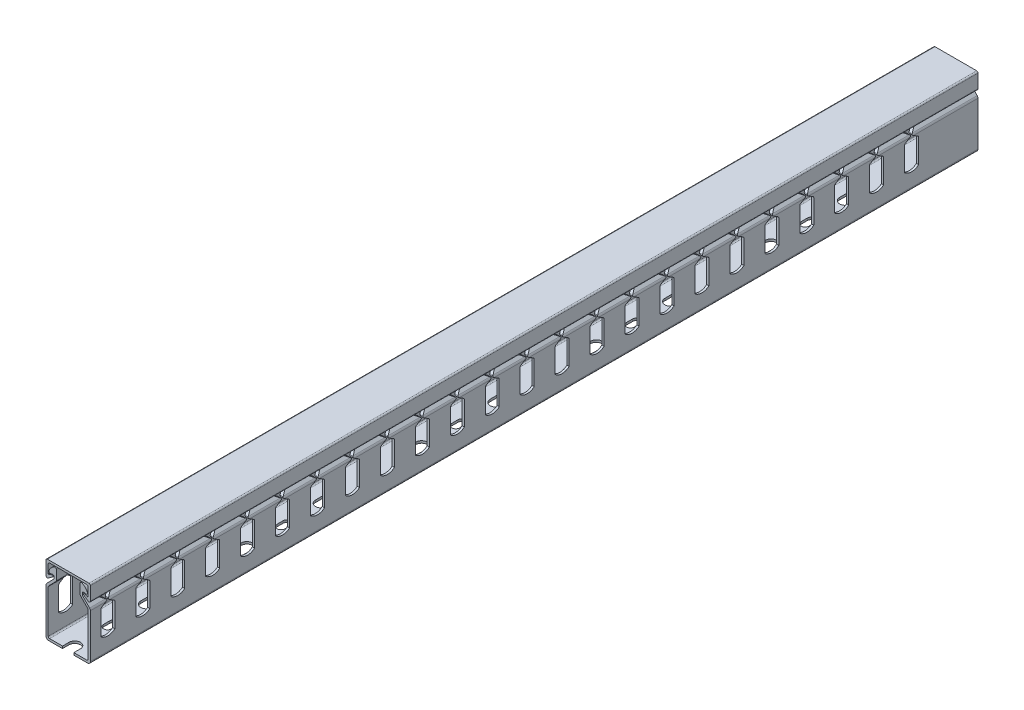
from build123d import *

# Parameters (mm, degrees)
BOSS_EXTRUDE1_DEPTH        = 254
BOSS_EXTRUDE1_DEPTH_BACK   = 254
BOSS_EXTRUDE1_2_DEPTH      = 254
BOSS_EXTRUDE1_2_DEPTH_BACK = 254
FILLET1_R                  = 0.254
FILLET2_R                  = 0.79375
FILLET3_R                  = 1.5875
FILLET4_R                  = 0.79375
CUT_EXTRUDE2_DEPTH         = 13.7
LPATTERN2_COUNT            = 24
LPATTERN2_PITCH            = 20
CUT_EXTRUDE3_DEPTH         = 1.27
CUT_EXTRUDE4_DEPTH         = 1.27
LPATTERN3_COUNT            = 11
LPATTERN3_PITCH            = 50


with BuildPart() as part:
    # Sketch5 → Boss-Extrude1 (new body, two sides)
    with BuildSketch(Plane.XY) as boss_extrude1_sk:
        with BuildLine():
            Line((-6.80847, 17.42825), (-6.80847, 11.601073654))
            Line((-6.80847, 11.601073654), (-11.43, 6.8817226))
            Line((-11.43, 6.8817226), (-11.43, -18.73))
            Line((-11.43, -18.73), (11.43, -18.73))
            Line((11.43, -18.73), (11.43, 6.8817226))
            Line((11.43, 6.8817226), (6.80847, 11.601073654))
            Line((6.80847, 11.601073654), (6.80847, 17.42825))
            ThreePointArc((6.80847, 17.42825), (7.19761808, 18.11113824), (7.983490721, 18.124433668))
            ThreePointArc((7.983490721, 18.124433668), (9.75568161, 16.763244384), (11.032082377, 14.929042133))
            ThreePointArc((11.032082377, 14.929042133), (10.954803473, 14.106067876), (10.187743463, 13.798045804))
            Line((10.187743463, 13.798045804), (8.07847, 14.151017128))
            Line((8.07847, 14.151017128), (8.07847, 12.119351053))
            Line((8.07847, 12.119351053), (12.7, 7.4))
            Line((12.7, 7.4), (12.7, -20))
            Line((12.7, -20), (-12.7, -20))
            Line((-12.7, -20), (-12.7, 7.4))
            Line((-12.7, 7.4), (-8.07847, 12.119351053))
            Line((-8.07847, 12.119351053), (-8.07847, 14.151017128))
            Line((-8.07847, 14.151017128), (-10.187743463, 13.798045804))
            ThreePointArc((-10.187743463, 13.798045804), (-10.954803473, 14.106067876), (-11.032082377, 14.929042133))
            ThreePointArc((-11.032082377, 14.929042133), (-9.75568161, 16.763244384), (-7.983490721, 18.124433668))
            ThreePointArc((-7.983490721, 18.124433668), (-7.19761808, 18.11113824), (-6.80847, 17.42825))
        make_face()
    extrude(amount=BOSS_EXTRUDE1_DEPTH)
    extrude(boss_extrude1_sk.sketch, amount=-BOSS_EXTRUDE1_DEPTH_BACK)

    # Fillet3
    fillet3_edges = [part.edges().sort_by_distance(p)[0] for p in [
        (12.7, 7.4, 0),
        (12.7, -20, 0),
        (-12.7, -20, 0),
        (-12.7, 7.4, 0),
    ]]
    fillet(fillet3_edges, radius=FILLET3_R)

    # Fillet4
    fillet4_edges = [part.edges().sort_by_distance(p)[0] for p in [
        (-6.80847, 11.601073654, 0),
        (-11.43, 6.8817226, 0),
        (-11.43, -18.73, 0),
        (11.43, -18.73, 0),
        (11.43, 6.8817226, 0),
        (6.80847, 11.601073654, 0),
        (8.07847, 14.151017128, 0),
        (-8.07847, 14.151017128, 0),
    ]]
    fillet(fillet4_edges, radius=FILLET4_R)

    # Sketch6 → Cut-Extrude2 (cut, symmetric)
    with BuildSketch(Plane(origin=(0, 0, 0), x_dir=(0, 0, -1), z_dir=(1, 0, 0))):
        with BuildLine():
            Line((-248, 20), (-248, 10.281402782))
            ThreePointArc((-248, 10.281402782), (-247.901317282, 9.898100634), (-247.629806522, 9.610106323))
            Line((-247.629806522, 9.610106323), (-244.658970247, 7.735648229))
            ThreePointArc((-244.658970247, 7.735648229), (-244.473873508, 7.4), (-244.658970247, 7.064351771))
            Line((-244.658970247, 7.064351771), (-247.629806522, 5.189893677))
            ThreePointArc((-247.629806522, 5.189893677), (-247.901317282, 4.901899366), (-248, 4.518597218))
            Line((-248, 4.518597218), (-248, -9.1796))
            ThreePointArc((-248, -9.1796), (-244, -10.707464045), (-240, -9.1796))
            Line((-240, -9.1796), (-240, 4.518597218))
            ThreePointArc((-240, 4.518597218), (-240.098682718, 4.901899366), (-240.370193478, 5.189893677))
            Line((-240.370193478, 5.189893677), (-243.341029753, 7.064351771))
            ThreePointArc((-243.341029753, 7.064351771), (-243.526126492, 7.4), (-243.341029753, 7.735648229))
            Line((-243.341029753, 7.735648229), (-240.370193478, 9.610106323))
            ThreePointArc((-240.370193478, 9.610106323), (-240.098682718, 9.898100634), (-240, 10.281402782))
            Line((-240, 10.281402782), (-240, 20))
            Line((-240, 20), (-248, 20))
        make_face()
    cut_extrude2 = extrude(amount=CUT_EXTRUDE2_DEPTH, both=True, mode=Mode.SUBTRACT)

    # LPattern2: Cut-Extrude2 ×24
    with Locations(*[(0, 0, -i * LPATTERN2_PITCH) for i in range(1, LPATTERN2_COUNT)]):
        add(cut_extrude2, mode=Mode.SUBTRACT)

    # Sketch7 → Cut-Extrude3 (cut)
    with BuildSketch(Plane.XZ.offset(20)):
        with BuildLine():
            Line((-3.25, 257.75), (-3.25, 250.25))
            ThreePointArc((-3.25, 250.25), (0, 247), (3.25, 250.25))
            Line((3.25, 250.25), (3.25, 257.75))
            ThreePointArc((3.25, 257.75), (0, 261), (-3.25, 257.75))
        make_face()
        with BuildLine():
            Line((-2.25, 231.5), (-2.25, 228))
            ThreePointArc((-2.25, 228), (0, 225.75), (2.25, 228))
            Line((2.25, 228), (2.25, 231.5))
            ThreePointArc((2.25, 231.5), (0, 233.75), (-2.25, 231.5))
        make_face()
    extrude(amount=-CUT_EXTRUDE3_DEPTH, mode=Mode.SUBTRACT)

    # Sketch8 → Cut-Extrude4 (cut)
    with BuildSketch(Plane.XZ.offset(20)):
        with BuildLine():
            Line((-2.25, 178.75), (-2.25, 182.25))
            ThreePointArc((-2.25, 182.25), (0, 184.5), (2.25, 182.25))
            Line((2.25, 182.25), (2.25, 178.75))
            ThreePointArc((2.25, 178.75), (0, 176.5), (-2.25, 178.75))
        make_face()
        with BuildLine():
            Line((3.25, 209.25), (3.25, 201.75))
            ThreePointArc((3.25, 201.75), (0, 198.5), (-3.25, 201.75))
            Line((-3.25, 201.75), (-3.25, 209.25))
            ThreePointArc((-3.25, 209.25), (0, 212.5), (3.25, 209.25))
        make_face()
    cut_extrude4 = extrude(amount=-CUT_EXTRUDE4_DEPTH, mode=Mode.SUBTRACT)

    # LPattern3: Cut-Extrude4 ×11
    with Locations(*[(0, 0, -i * LPATTERN3_PITCH) for i in range(1, LPATTERN3_COUNT)]):
        add(cut_extrude4, mode=Mode.SUBTRACT)


with BuildPart() as body_2:
    # Sketch5 → Boss-Extrude1 2 (new body, two sides)
    with BuildSketch(Plane.XY) as boss_extrude1_2_sk:
        with BuildLine():
            Line((-12.7, 20), (-12.7, 11.49227))
            ThreePointArc((-12.7, 11.49227), (-12.263515638, 10.783467964), (-11.434109413, 10.854208617))
            Line((-11.434109413, 10.854208617), (-8.751188909, 12.839465357))
            ThreePointArc((-8.751188909, 12.839465357), (-8.610572709, 13.282073626), (-8.98688149, 13.554225599))
            ThreePointArc((-8.98688149, 13.554225599), (-9.873382015, 13.411834461), (-10.670699038, 12.998985842))
            Line((-10.670699038, 12.998985842), (-11.43, 12.437132686))
            Line((-11.43, 12.437132686), (-11.43, 18.73))
            Line((-11.43, 18.73), (11.43, 18.73))
            Line((11.43, 18.73), (11.43, 12.437132686))
            Line((11.43, 12.437132686), (10.670699038, 12.998985842))
            ThreePointArc((10.670699038, 12.998985842), (9.873382015, 13.411834461), (8.98688149, 13.554225599))
            ThreePointArc((8.98688149, 13.554225599), (8.610572709, 13.282073626), (8.751188909, 12.839465357))
            Line((8.751188909, 12.839465357), (11.434109413, 10.854208617))
            ThreePointArc((11.434109413, 10.854208617), (12.263515638, 10.783467964), (12.7, 11.49227))
            Line((12.7, 11.49227), (12.7, 20))
            Line((12.7, 20), (-12.7, 20))
        make_face()
    extrude(amount=BOSS_EXTRUDE1_2_DEPTH)
    extrude(boss_extrude1_2_sk.sketch, amount=-BOSS_EXTRUDE1_2_DEPTH_BACK)

    # Fillet1
    fillet1_edges = [body_2.edges().sort_by_distance(p)[0] for p in [
        (11.43, 12.437132686, 0),
        (-11.43, 12.437132686, 0),
    ]]
    fillet(fillet1_edges, radius=FILLET1_R)

    # Fillet2
    fillet2_edges = [body_2.edges().sort_by_distance(p)[0] for p in [
        (12.7, 20, 0),
        (11.43, 18.73, 0),
        (-11.43, 18.73, 0),
        (-12.7, 20, 0),
    ]]
    fillet(fillet2_edges, radius=FILLET2_R)


solid = Compound([part.part, body_2.part])
